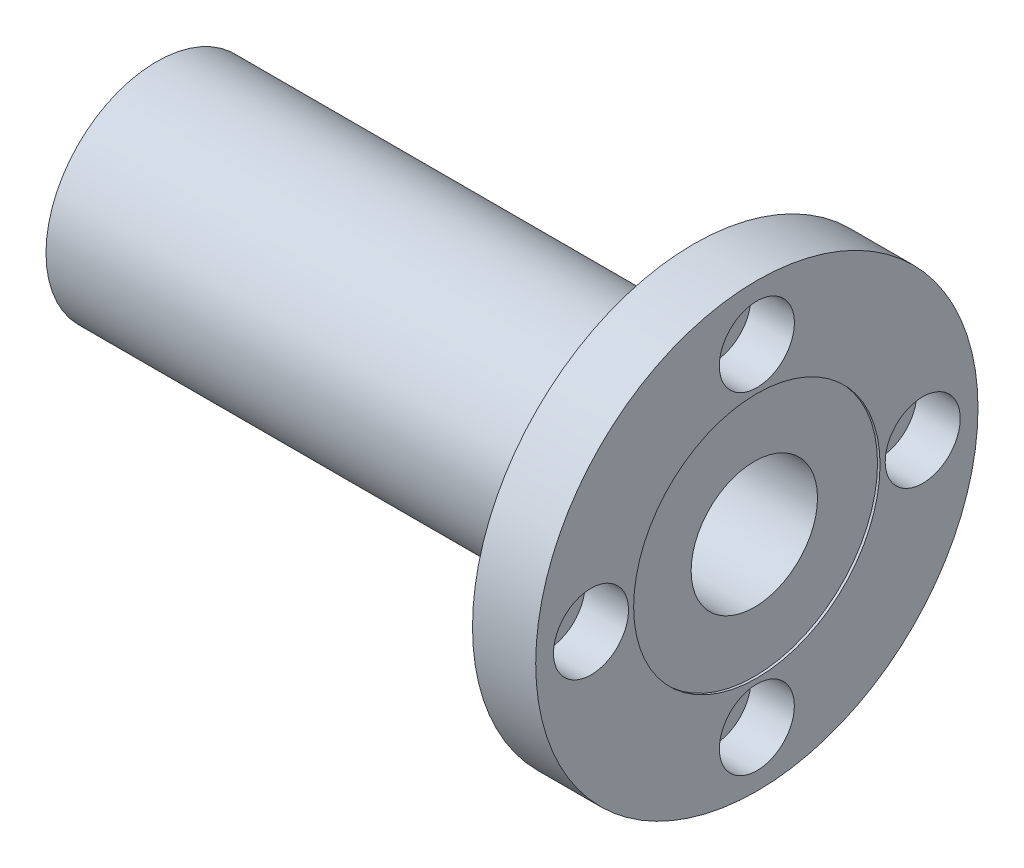
from build123d import *

# Parameters (mm, degrees)
MOUNTING_HOLE_PATTERN_COUNT = 4
SKETCH9_R                   = 12.3825
SHAFT_DIA_DEPTH             = 0.254


with BuildPart() as part:
    # Sketch1 → BASE-FLANGE (revolve)
    with BuildSketch(Plane.XY, mode=Mode.PRIVATE) as base_flange_sk:
        Polygon((-30.1625, -11.1125), (23.8125, -11.1125), (23.8125, -22.225), (30.1625, -22.225), (30.1625, -6.35), (-30.1625, -6.35), align=None)
    revolve(base_flange_sk.sketch.rotate(Axis((-10.390811595, 0, 0), (1, 0, 0)), 270), axis=Axis((-10.390811595, 0, 0), (1, 0, 0)))  # turned: the seam where the file's is

    # Sketch10 → MOUNTING-HOLE (revolve, cut)
    with BuildSketch(Plane.XY, mode=Mode.PRIVATE) as mounting_hole_sk:
        Polygon((30.1625, 20.43938), (25.79624, 20.43938), (25.79624, 19.05), (23.8125, 19.05), (23.8125, 16.66875), (30.1625, 16.66875), align=None)
    mounting_hole = revolve(mounting_hole_sk.sketch.rotate(Axis((7.205320248, 16.66875, 0), (1, 0, 0)), 90), axis=Axis((7.205320248, 16.66875, 0), (1, 0, 0)), mode=Mode.SUBTRACT)  # turned: the seam where the file's is

    # MOUNTING-HOLE PATTERN: MOUNTING-HOLE ×4 about axis
    mounting_hole_pattern_axis = Axis((0, 0, 0), (1, 0, 0))
    for i in range(1, MOUNTING_HOLE_PATTERN_COUNT):
        add(mounting_hole.rotate(mounting_hole_pattern_axis, i * 360 / MOUNTING_HOLE_PATTERN_COUNT), mode=Mode.SUBTRACT)

    # Sketch9 → SHAFT DIA (cut)
    with BuildSketch(Plane(origin=(30.1625, 0, 0), x_dir=(0, 0, -1), z_dir=(1, 0, 0))):
        Circle(SKETCH9_R)
    extrude(amount=-SHAFT_DIA_DEPTH, mode=Mode.SUBTRACT)


solid = part.part
